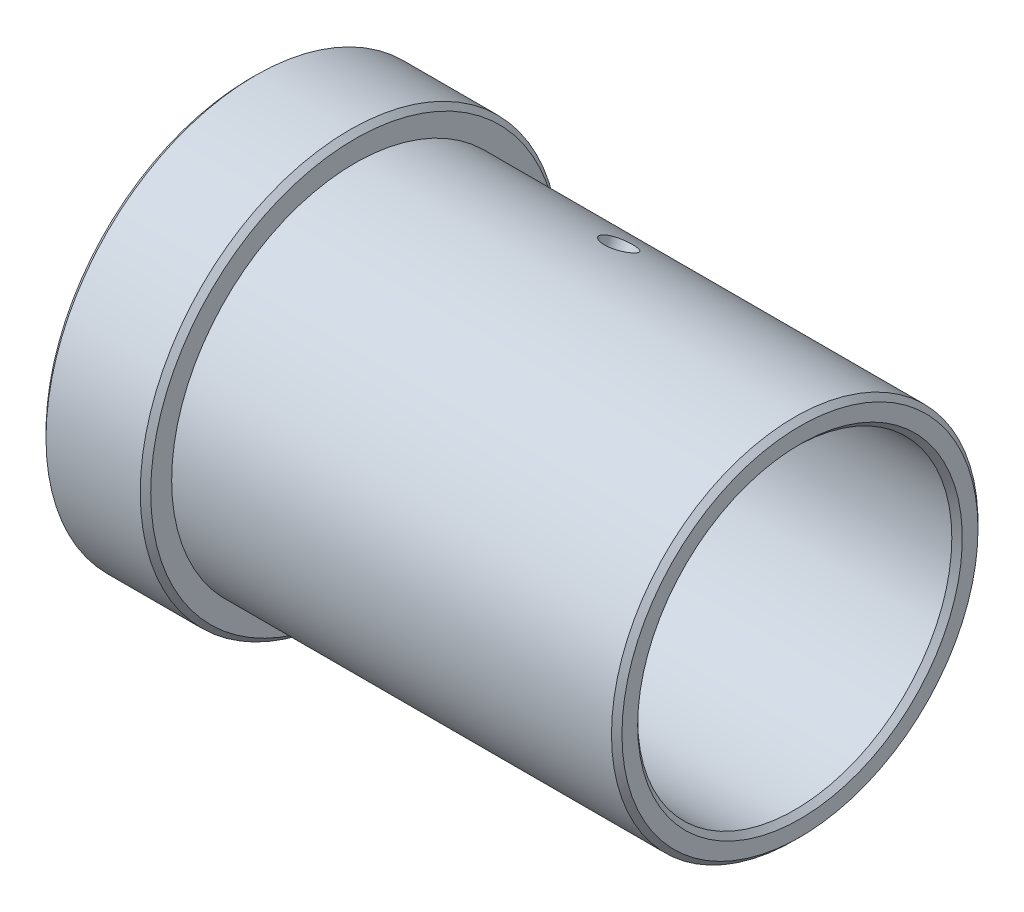
from build123d import *

# Parameters (mm, degrees)
CHAMFER_1_SIZE           = 1
SKETCH_2_R               = 3
CUT_EXTRUDE_1_DEPTH      = 10
CUT_EXTRUDE_1_DEPTH_BACK = 108


with BuildPart() as part:
    # Эскиз1 → Повернуть1 (revolve)
    with BuildSketch(Plane.XY):
        Polygon((0, 40), (0, 30), (105, 30), (105, 35), (20, 35), (20, 40), align=None)
    revolve(axis=Axis((0, 0, 0), (1, 0, 0)))

    # Фаска1
    chamfer_1_edges = [part.edges().sort_by_distance(p)[0] for p in [
        (20, -40, 0),
        (105, -35, 0),
        (105, -30, 0),
        (0, -30, 0),
        (0, -40, 0),
    ]]
    chamfer(chamfer_1_edges, length=CHAMFER_1_SIZE)

    # Эскиз2 → Вырез-Вытянуть1 (cut, two sides)
    with BuildSketch(Plane(origin=(110, 102, -50), x_dir=(1, 0, 0), z_dir=(0, 0.897920723, -0.440157217))) as cut_extrude_1_sk:
        with Locations((-55, 0)):
            Circle(SKETCH_2_R)
    extrude(amount=CUT_EXTRUDE_1_DEPTH, mode=Mode.SUBTRACT)
    extrude(cut_extrude_1_sk.sketch, amount=-CUT_EXTRUDE_1_DEPTH_BACK, mode=Mode.SUBTRACT)


solid = part.part
